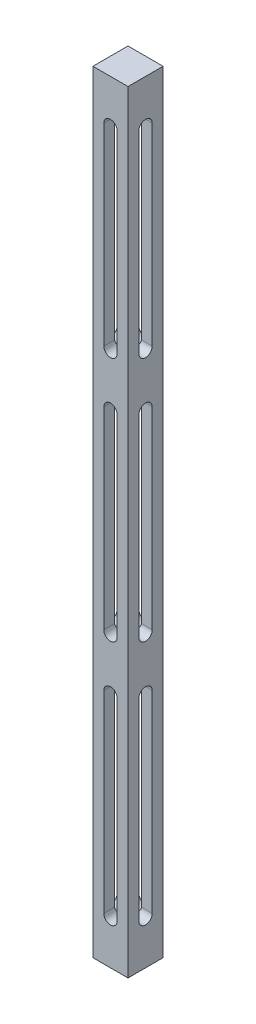
from build123d import *

# Parameters (mm, degrees)
SKETCH1_W           = 12.7
SKETCH1_H           = 12.7
BOSS_EXTRUDE1_DEPTH = 279.4
CUT_EXTRUDE1_DEPTH  = 13.7
CUT_EXTRUDE2_DEPTH  = 13.7
LPATTERN1_COUNT     = 3
LPATTERN1_PITCH     = 88.9


with BuildPart() as part:
    # Sketch1 → Boss-Extrude1 (new body)
    with BuildSketch(Plane(origin=(0, 0, 0), x_dir=(1, 0, 0), z_dir=(0, 1, 0))):
        Rectangle(SKETCH1_W, SKETCH1_H)
    extrude(amount=BOSS_EXTRUDE1_DEPTH)

    # Sketch2 → Cut-Extrude1 (cut, through all)
    with BuildSketch(Plane(origin=(0, 0, -6.35), x_dir=(-1, 0, 0), z_dir=(0, 0, -1))):
        with BuildLine():
            Line((-2.413, 263.525), (-2.413, 193.675))
            ThreePointArc((-2.413, 193.675), (0, 191.262), (2.413, 193.675))
            Line((2.413, 193.675), (2.413, 263.525))
            ThreePointArc((2.413, 263.525), (0, 265.938), (-2.413, 263.525))
        make_face()
    cut_extrude1 = extrude(amount=-CUT_EXTRUDE1_DEPTH, mode=Mode.SUBTRACT)

    # Sketch3 → Cut-Extrude2 (cut, through all)
    with BuildSketch(Plane(origin=(6.35, 0, 0), x_dir=(0, 0, -1), z_dir=(1, 0, 0))):
        with BuildLine():
            Line((-2.413, 263.525), (-2.413, 193.675))
            ThreePointArc((-2.413, 193.675), (0, 191.262), (2.413, 193.675))
            Line((2.413, 193.675), (2.413, 263.525))
            ThreePointArc((2.413, 263.525), (0, 265.938), (-2.413, 263.525))
        make_face()
    cut_extrude2 = extrude(amount=-CUT_EXTRUDE2_DEPTH, mode=Mode.SUBTRACT)

    # LPattern1: Cut-Extrude1, Cut-Extrude2 ×3
    with Locations(*[(0, -i * LPATTERN1_PITCH, 0) for i in range(1, LPATTERN1_COUNT)]):
        add(cut_extrude1, mode=Mode.SUBTRACT)
        add(cut_extrude2, mode=Mode.SUBTRACT)


solid = part.part
